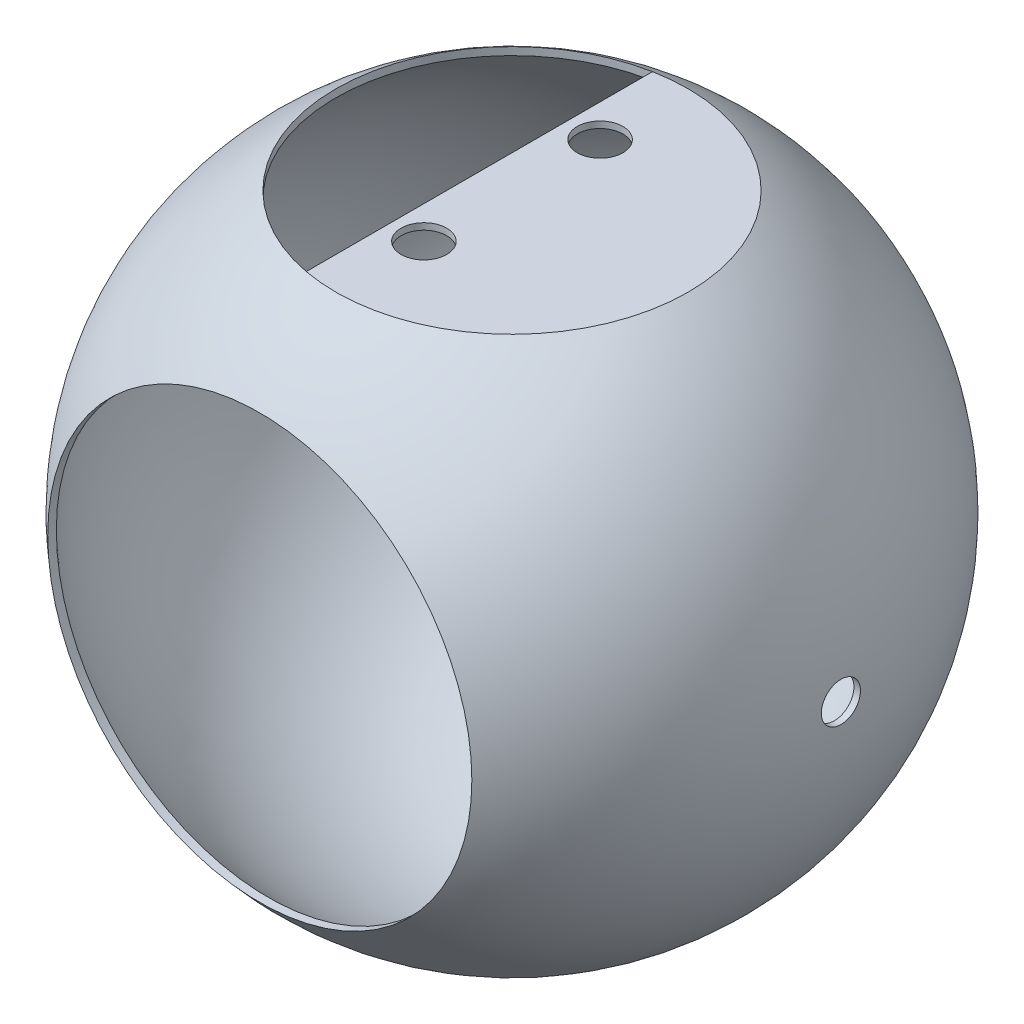
from build123d import *

# Parameters (mm, degrees)
CUT_EXTRUDE7_REACH      = 103
SKETCH5_R               = 54
CUT_EXTRUDE8_REACH      = 103
SKETCH6_R               = 65
BOSS_EXTRUDE1_DEPTH     = 2
SKETCH9_R               = 6
CUT_EXTRUDE9_DEPTH      = 200
CUT_EXTRUDE9_DEPTH_BACK = 200
SKETCH10_R              = 7
CUT_EXTRUDE10_DEPTH     = 20


with BuildPart() as part:
    # Sketch2 → Globe (revolve)
    with BuildSketch(Plane(origin=(0, 0, 0), x_dir=(1, 0, 0), z_dir=(0, 1, 0))):
        with BuildLine():
            ThreePointArc((0, -101), (101, 0), (0, 101))
            Line((0, 101), (0, 99))
            ThreePointArc((0, 99), (99, 0), (0, -99))
            Line((0, -99), (0, -101))
        make_face()
    revolve(axis=Axis((0, 0, 100), (0, 0, -1)))

    # Sketch5 → Cut-Extrude7 (cut, up to next)
    with BuildSketch(Plane(origin=(0, 0, 0), x_dir=(1, 0, 0), z_dir=(0, 1, 0)), mode=Mode.PRIVATE) as cut_extrude7_sk1:
        Circle(SKETCH5_R)
    cut_extrude7_tool1 = extrude(cut_extrude7_sk1.sketch, amount=CUT_EXTRUDE7_REACH, mode=Mode.PRIVATE) & part.part
    add(cut_extrude7_tool1.solids().sort_by_distance((0, 0, 0))[0], mode=Mode.SUBTRACT)

    # Sketch6 → Cut-Extrude8 (cut, up to next)
    with BuildSketch(Plane.XY, mode=Mode.PRIVATE) as cut_extrude8_sk1:
        Circle(SKETCH6_R)
    cut_extrude8_tool1 = extrude(cut_extrude8_sk1.sketch, amount=CUT_EXTRUDE8_REACH, mode=Mode.PRIVATE) & part.part
    add(cut_extrude8_tool1.solids().sort_by_distance((0, 0, 0))[0], mode=Mode.SUBTRACT)

    # Sketch7 → Boss-Extrude1 (add)
    with BuildSketch(Plane(origin=(0, 85.352211453, 0), x_dir=(-1, 0, 0), z_dir=(0, -1, 0))):
        with BuildLine():
            Line((10, -53.065996646), (10, 53.065996646))
            ThreePointArc((10, 53.065996646), (-54, 0), (10, -53.065996646))
        make_face()
    extrude(amount=BOSS_EXTRUDE1_DEPTH)

    # Sketch9 → Cut-Extrude9 (cut, two sides)
    with BuildSketch(Plane(origin=(0, 0, 0), x_dir=(0, 0, -1), z_dir=(1, 0, 0))) as cut_extrude9_sk:
        Circle(SKETCH9_R)
    extrude(amount=CUT_EXTRUDE9_DEPTH, mode=Mode.SUBTRACT)
    extrude(cut_extrude9_sk.sketch, amount=-CUT_EXTRUDE9_DEPTH_BACK, mode=Mode.SUBTRACT)

    # Sketch10 → Cut-Extrude10 (cut)
    with BuildSketch(Plane(origin=(0, 85.352211453, 0), x_dir=(1, 0, 0), z_dir=(0, 1, 0))):
        with Locations((0, 27)):
            Circle(SKETCH10_R)
        with Locations((0, -27)):
            Circle(SKETCH10_R)
    extrude(amount=-CUT_EXTRUDE10_DEPTH, mode=Mode.SUBTRACT)


solid = part.part
